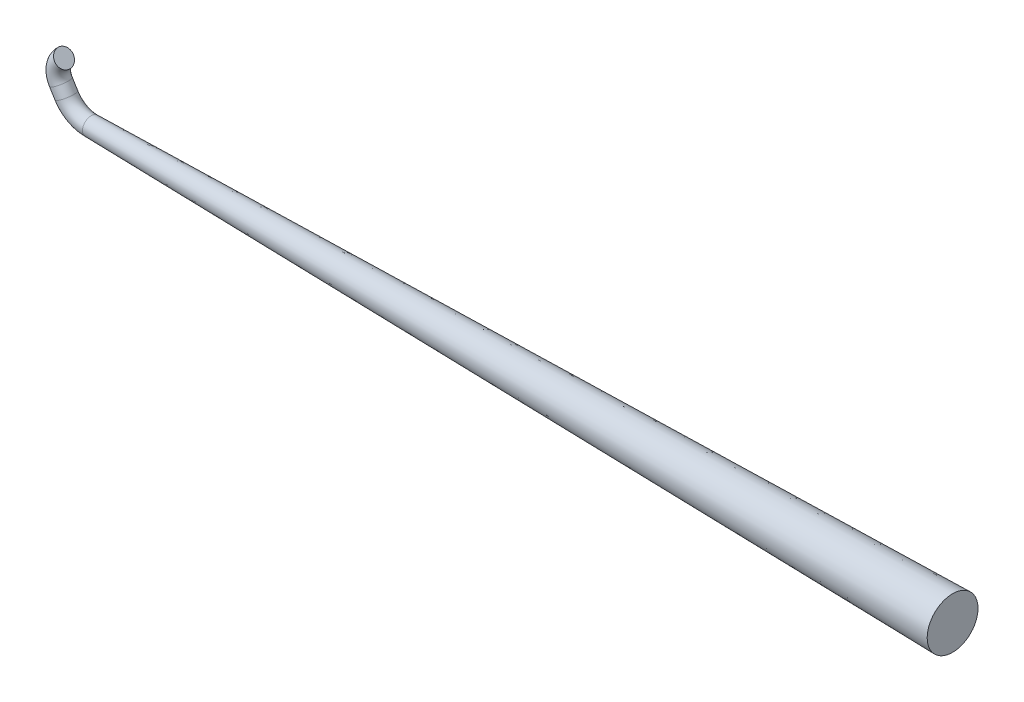
from build123d import *

# Parameters (mm, degrees)
SKETCH9_R = 0.438270911


with BuildPart() as part:
    # Sketch8 → Revolve1 (revolve)
    with BuildSketch(Plane.XY):
        Polygon((-30.328870103, 22.315728281), (-73.712534729, 22.315728281), (-73.712534729, 22.753999191), (-30.328870103, 23.59564563), align=None)
    revolve(axis=Axis((-30.328870103, 22.315728281, 0), (-1, 0, 0)))

    # Sweep1: sweep along a path in Sketch1
    with BuildLine(Plane.XY) as sweep1_path:
        ThreePointArc((-73.712534729, 22.315728281), (-74.42590498, 22.500925633), (-74.95910268, 23.009743269))
        Line((-74.95910268, 23.009743269), (-75.236356936, 23.457133918))
        ThreePointArc((-75.236356936, 23.457133918), (-75.361313032, 24.047487738), (-75.080614975, 24.581660239))
    # Sketch9 → Sweep1 (sweep)
    with BuildSketch(Plane.ZY.offset(73.712534729)):
        with Locations((0, 22.315728281)):
            Circle(SKETCH9_R)
    sweep(path=sweep1_path.line)


solid = part.part
